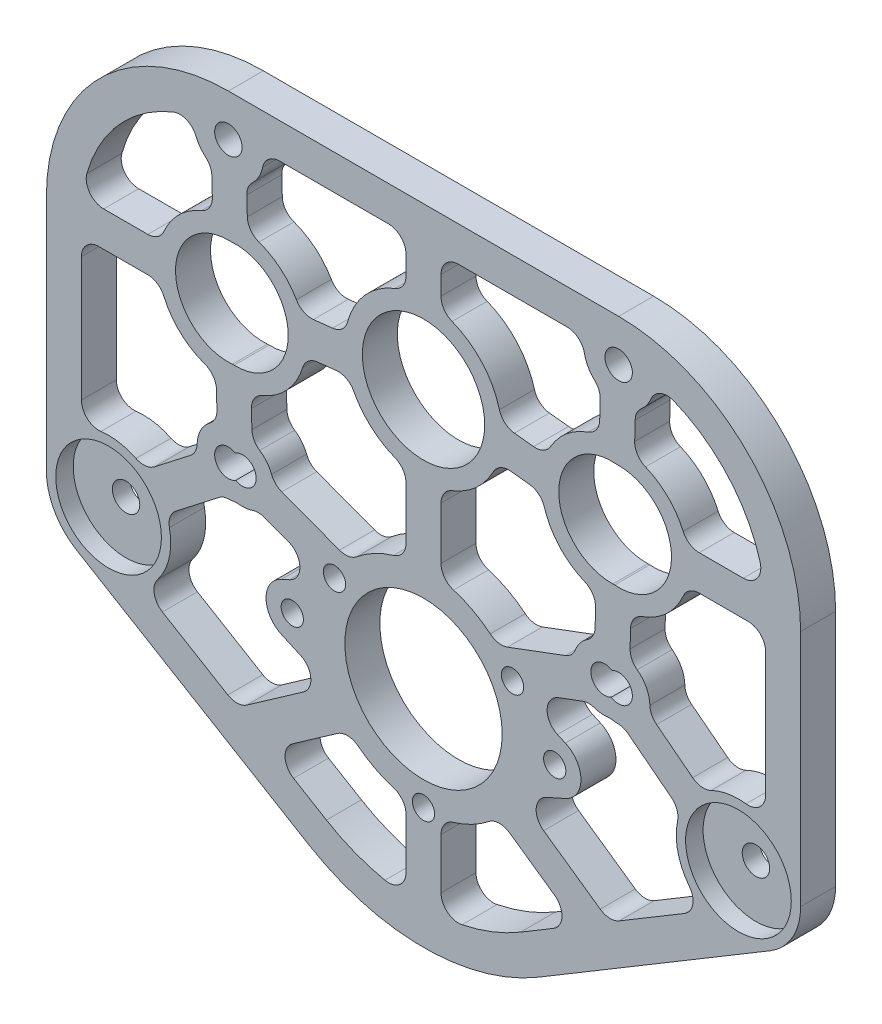
from build123d import *

# Parameters (mm, degrees)
BOSS_EXTRUDE1_DEPTH        = 6.35
M18_CLEARANCE_HOLE1_D      = 19.177
M18_CLEARANCE_HOLE1_DEPTH  = 6.35
M18_CLEARANCE_HOLE2_D      = 19.177
M18_CLEARANCE_HOLE2_DEPTH  = 6.35
CUT_EXTRUDE1_DEPTH         = 7.35
CUT_EXTRUDE2_DEPTH         = 7.35
CUT_EXTRUDE3_DEPTH         = 7.35
CUT_EXTRUDE4_DEPTH         = 7.35
CUT_EXTRUDE5_DEPTH         = 7.35
CUT_EXTRUDE6_DEPTH         = 7.35
CUT_EXTRUDE7_DEPTH         = 7.35
CUT_EXTRUDE8_DEPTH         = 7.35
CUT_EXTRUDE9_DEPTH         = 7.35
CUT_EXTRUDE10_DEPTH        = 7.35
CUT_EXTRUDE11_DEPTH        = 7.35
CUT_EXTRUDE12_DEPTH        = 7.35
SKETCH18_W                 = 9.5885
SKETCH18_H                 = 6.35
SKETCH19_W                 = 9.5885
SKETCH19_H                 = 6.35
M25_CLEARANCE_HOLE1_D      = 28.5496
M25_CLEARANCE_HOLE1_DEPTH  = 6.35
HOLE1_D                    = 4.9784
HOLE1_DEPTH                = 6.35
HOLE2_D                    = 4.9784
HOLE2_DEPTH                = 6.35
M20_CLEARANCE_HOLE1_D      = 22.1996
M20_CLEARANCE_HOLE1_DEPTH  = 6.35
M3_5_CLEARANCE_HOLE1_D     = 4.0386
M3_5_CLEARANCE_HOLE1_DEPTH = 6.35
HOLE3_D                    = 4.9784
HOLE3_DEPTH                = 6.35
HOLE3_CBORE_D              = 19.177
HOLE3_CBORE_DEPTH          = 3.175
FILLET1_R                  = 3.175
FILLET2_R                  = 11.28150672
FILLET3_R                  = 33.02
FILLET4_R                  = 40.64


with BuildPart() as part:
    # Sketch1 → Boss-Extrude1 (new body)
    with BuildSketch(Plane.XY.offset(3.175)):
        Polygon((0, -94.408741711), (68.43150672, -53.435111347), (68.43150672, 29.21), (-68.43150672, 29.21), (-68.43150672, -53.435111347), align=None)
    extrude(amount=-BOSS_EXTRUDE1_DEPTH)

    # M18 Clearance Hole1
    with Locations(Plane.XY.offset(3.175)):
        with Locations((34.132374495, -3.7777713)):
            Hole(M18_CLEARANCE_HOLE1_D / 2, depth=M18_CLEARANCE_HOLE1_DEPTH)

    # M18 Clearance Hole2
    with Locations(Plane.XY.offset(3.175)):
        with Locations((-34.132374495, -3.7777713)):
            Hole(M18_CLEARANCE_HOLE2_D / 2, depth=M18_CLEARANCE_HOLE2_DEPTH)

    # Sketch6 → Cut-Extrude1 (cut, through all)
    with BuildSketch(Plane.XY.offset(3.175)):
        with BuildLine():
            Line((17.615095968, -76.46039371), (23.582535178, -72.887366311))
            ThreePointArc((23.582535178, -72.887366311), (25.12448686, -70.276593795), (23.772612959, -67.562522116))
            Line((23.772612959, -67.562522116), (13.565480909, -60.415411311))
            ThreePointArc((13.565480909, -60.415411311), (8.796311082, -63.938356372), (3.175, -65.824353311))
            Line((3.175, -65.824353311), (3.175, -81.183492849))
            ThreePointArc((3.175, -81.183492849), (10.65992209, -79.631752135), (17.615095968, -76.46039371))
        make_face()
    extrude(amount=-CUT_EXTRUDE1_DEPTH, mode=Mode.SUBTRACT)

    # Sketch7 → Cut-Extrude2 (cut, through all)
    with BuildSketch(Plane.XY.offset(3.175)):
        with BuildLine():
            Line((31.913026081, 8.791294889), (32.098999956, 16.172454528))
            ThreePointArc((32.098999956, 16.172454528), (29.588611428, 19.056940502), (29.189802773, 22.86))
            Line((29.189802773, 22.86), (3.175, 22.86))
            Line((3.175, 22.86), (3.175, 13.91722997))
            ThreePointArc((3.175, 13.91722997), (10.627125942, 9.53069301), (14.179496739, 1.646750514))
            Line((14.179496739, 1.646750514), (22.206916622, 0.770897382))
            ThreePointArc((22.206916622, 0.770897382), (26.002148159, 6.061250602), (31.913026081, 8.791294889))
        make_face()
    extrude(amount=-CUT_EXTRUDE2_DEPTH, mode=Mode.SUBTRACT)

    # Sketch8 → Cut-Extrude3 (cut, through all)
    with BuildSketch(Plane.XY.offset(3.175)):
        with BuildLine():
            Line((13.435865001, -33.535984871), (27.242817605, -28.366892024))
            ThreePointArc((27.242817605, -28.366892024), (28.50767908, -25.512466465), (31.092824958, -23.761854968))
            Line((31.092824958, -23.761854968), (31.282869747, -16.219123917))
            ThreePointArc((31.282869747, -16.219123917), (24.724376238, -12.403111934), (21.49092773, -5.538667651))
            Line((21.49092773, -5.538667651), (13.490750449, -4.665786896))
            ThreePointArc((13.490750449, -4.665786896), (9.53069301, -10.627125942), (3.175, -13.91722997))
            Line((3.175, -13.91722997), (3.175, -28.257246689))
            ThreePointArc((3.175, -28.257246689), (8.714727662, -30.10102368), (13.435865001, -33.535984871))
        make_face()
    extrude(amount=-CUT_EXTRUDE3_DEPTH, mode=Mode.SUBTRACT)

    # Sketch9 → Cut-Extrude4 (cut, through all)
    with BuildSketch(Plane.XY.offset(3.175)):
        with BuildLine():
            Line((62.08150672, -6.985000553), (47.775965215, -6.97655939))
            ThreePointArc((47.775965215, -6.97655939), (44.087544958, -13.171265552), (37.630855133, -16.379066189))
            Line((37.630855133, -16.379066189), (37.440810345, -23.921797239))
            ThreePointArc((37.440810345, -23.921797239), (40.402375317, -26.531494393), (40.940094019, -30.442024396))
            Line((40.940094019, -30.442024396), (50.544309752, -37.895459645))
            ThreePointArc((50.544309752, -37.895459645), (56.174637648, -35.801535693), (62.08150672, -36.894242192))
            Line((62.08150672, -36.894242192), (62.08150672, -6.985000553))
        make_face()
    extrude(amount=-CUT_EXTRUDE4_DEPTH, mode=Mode.SUBTRACT)

    # Sketch10 → Cut-Extrude5 (cut, through all)
    with BuildSketch(Plane.XY.offset(3.175)):
        with BuildLine():
            Line((47.771628677, -0.626555725), (58.029583648, -0.63260856))
            ThreePointArc((58.029583648, -0.63260856), (60.561320425, 0.623949714), (61.088207147, 3.400822089))
            ThreePointArc((61.088207147, 3.400822089), (53.945197407, 15.367883343), (41.741154103, 22.098))
            ThreePointArc((41.741154103, 22.098), (40.995831795, 18.567118353), (38.446985343, 16.012512256))
            Line((38.446985343, 16.012512256), (38.261011468, 8.631352617))
            ThreePointArc((38.261011468, 8.631352617), (44.31433789, 5.335847659), (47.771628677, -0.626555725))
        make_face()
    extrude(amount=-CUT_EXTRUDE5_DEPTH, mode=Mode.SUBTRACT)

    # Sketch11 → Cut-Extrude6 (cut, through all)
    with BuildSketch(Plane.XY.offset(3.175)):
        with BuildLine():
            Line((-32.098999956, 16.172454528), (-31.913026081, 8.791294889))
            ThreePointArc((-31.913026081, 8.791294889), (-26.002148159, 6.061250602), (-22.206916622, 0.770897382))
            Line((-22.206916622, 0.770897382), (-14.179496739, 1.646750514))
            ThreePointArc((-14.179496739, 1.646750514), (-10.627125942, 9.53069301), (-3.175, 13.91722997))
            Line((-3.175, 13.91722997), (-3.175, 22.86))
            Line((-3.175, 22.86), (-29.189802773, 22.86))
            ThreePointArc((-29.189802773, 22.86), (-29.588611428, 19.056940502), (-32.098999956, 16.172454528))
        make_face()
    extrude(amount=-CUT_EXTRUDE6_DEPTH, mode=Mode.SUBTRACT)

    # Sketch12 → Cut-Extrude7 (cut, through all)
    with BuildSketch(Plane.XY.offset(3.175)):
        with BuildLine():
            Line((-47.775965215, -6.97655939), (-62.08150672, -6.985000553))
            Line((-62.08150672, -6.985000553), (-62.08150672, -36.894242192))
            ThreePointArc((-62.08150672, -36.894242192), (-56.174637648, -35.801535693), (-50.544309752, -37.895459645))
            Line((-50.544309752, -37.895459645), (-40.940094019, -30.442024396))
            ThreePointArc((-40.940094019, -30.442024396), (-40.402375317, -26.531494393), (-37.440810345, -23.921797239))
            Line((-37.440810345, -23.921797239), (-37.630855133, -16.379066189))
            ThreePointArc((-37.630855133, -16.379066189), (-44.087544958, -13.171265552), (-47.775965215, -6.97655939))
        make_face()
    extrude(amount=-CUT_EXTRUDE7_DEPTH, mode=Mode.SUBTRACT)

    # Sketch13 → Cut-Extrude8 (cut, through all)
    with BuildSketch(Plane.XY.offset(3.175)):
        with BuildLine():
            Line((-38.261011468, 8.631352617), (-38.446985343, 16.012512256))
            ThreePointArc((-38.446985343, 16.012512256), (-40.995831795, 18.567118353), (-41.741154103, 22.098))
            ThreePointArc((-41.741154103, 22.098), (-53.945197407, 15.367883343), (-61.088207147, 3.400822089))
            ThreePointArc((-61.088207147, 3.400822089), (-60.561320425, 0.623949714), (-58.029583648, -0.63260856))
            Line((-58.029583648, -0.63260856), (-47.771628677, -0.626555725))
            ThreePointArc((-47.771628677, -0.626555725), (-44.31433789, 5.335847659), (-38.261011468, 8.631352617))
        make_face()
    extrude(amount=-CUT_EXTRUDE8_DEPTH, mode=Mode.SUBTRACT)

    # Sketch14 → Cut-Extrude9 (cut, through all)
    with BuildSketch(Plane.XY.offset(3.175)):
        with BuildLine():
            Line((-27.242817605, -28.366892024), (-13.435865001, -33.535984871))
            ThreePointArc((-13.435865001, -33.535984871), (-8.714727662, -30.10102368), (-3.175, -28.257246689))
            Line((-3.175, -28.257246689), (-3.175, -13.91722997))
            ThreePointArc((-3.175, -13.91722997), (-9.53069301, -10.627125942), (-13.490750449, -4.665786896))
            Line((-13.490750449, -4.665786896), (-21.49092773, -5.538667651))
            ThreePointArc((-21.49092773, -5.538667651), (-24.724376238, -12.403111934), (-31.282869747, -16.219123917))
            Line((-31.282869747, -16.219123917), (-31.092824958, -23.761854968))
            ThreePointArc((-31.092824958, -23.761854968), (-28.50767908, -25.512466465), (-27.242817605, -28.366892024))
        make_face()
    extrude(amount=-CUT_EXTRUDE9_DEPTH, mode=Mode.SUBTRACT)

    # Sketch15 → Cut-Extrude10 (cut, through all)
    with BuildSketch(Plane.XY.offset(3.175)):
        with BuildLine():
            Line((-13.565480909, -60.415411311), (-23.772612959, -67.562522116))
            ThreePointArc((-23.772612959, -67.562522116), (-25.12448686, -70.276593795), (-23.582535178, -72.887366311))
            Line((-23.582535178, -72.887366311), (-17.615095968, -76.46039371))
            ThreePointArc((-17.615095968, -76.46039371), (-10.65992209, -79.631752135), (-3.175, -81.183492849))
            Line((-3.175, -81.183492849), (-3.175, -65.824353311))
            ThreePointArc((-3.175, -65.824353311), (-8.796311082, -63.938356372), (-13.565480909, -60.415411311))
        make_face()
    extrude(amount=-CUT_EXTRUDE10_DEPTH, mode=Mode.SUBTRACT)

    # Sketch16 → Cut-Extrude11 (cut, through all)
    with BuildSketch(Plane.XY.offset(3.175)):
        with BuildLine():
            Line((-22.318905678, -52.92668905), (-25.757705391, -51.387934946))
            ThreePointArc((-25.757705391, -51.387934946), (-28.574996604, -47.035112368), (-25.747316689, -42.689031322))
            Line((-25.747316689, -42.689031322), (-24.314652477, -42.052062118))
            ThreePointArc((-24.314652477, -42.052062118), (-22.430965024, -39.055443853), (-24.491321085, -36.177435453))
            Line((-24.491321085, -36.177435453), (-30.080779683, -34.084835349))
            ThreePointArc((-30.080779683, -34.084835349), (-31.982139058, -34.742357841), (-33.993393871, -34.693805028))
            ThreePointArc((-33.993393871, -34.693805028), (-35.100270784, -34.865642654), (-36.219319476, -34.816300045))
            Line((-36.219319476, -34.816300045), (-46.651162402, -42.912022583))
            ThreePointArc((-46.651162402, -42.912022583), (-46.401481265, -50.467422079), (-50.977977716, -56.484238717))
            Line((-50.977977716, -56.484238717), (-33.752087956, -66.798307098))
            Line((-33.752087956, -66.798307098), (-21.794604087, -58.425586755))
            ThreePointArc((-21.794604087, -58.425586755), (-20.455043555, -55.523420059), (-22.318905678, -52.92668905))
        make_face()
    extrude(amount=-CUT_EXTRUDE11_DEPTH, mode=Mode.SUBTRACT)

    # Sketch17 → Cut-Extrude12 (cut, through all)
    with BuildSketch(Plane(origin=(0, 0, -3.175), x_dir=(-1, 0, 0), z_dir=(0, 0, -1))):
        with BuildLine():
            Line((-33.752087956, -66.798307098), (-21.794604087, -58.425586755))
            ThreePointArc((-21.794604087, -58.425586755), (-20.455043555, -55.523420059), (-22.318905678, -52.92668905))
            Line((-22.318905678, -52.92668905), (-25.757705391, -51.387934946))
            ThreePointArc((-25.757705391, -51.387934946), (-28.574996604, -47.035112368), (-25.747316689, -42.689031322))
            Line((-25.747316689, -42.689031322), (-24.314652477, -42.052062118))
            ThreePointArc((-24.314652477, -42.052062118), (-22.430965024, -39.055443853), (-24.491321085, -36.177435453))
            Line((-24.491321085, -36.177435453), (-30.080779683, -34.084835349))
            ThreePointArc((-30.080779683, -34.084835349), (-31.982139058, -34.742357841), (-33.993393871, -34.693805028))
            ThreePointArc((-33.993393871, -34.693805028), (-35.100270784, -34.865642654), (-36.219319476, -34.816300045))
            Line((-36.219319476, -34.816300045), (-46.651162402, -42.912022583))
            ThreePointArc((-46.651162402, -42.912022583), (-46.401481265, -50.467422079), (-50.977977716, -56.484238717))
            Line((-50.977977716, -56.484238717), (-33.752087956, -66.798307098))
        make_face()
    extrude(amount=-CUT_EXTRUDE12_DEPTH, mode=Mode.SUBTRACT)

    # Sketch18 → Cut-Revolve1 (revolve, cut)
    with BuildSketch(Plane(origin=(0, -3.81, 0), x_dir=(1, 0, 0), z_dir=(0, 1, 0))):
        with Locations((40.20575672, 0)):
            Rectangle(SKETCH18_W, SKETCH18_H)
    revolve(axis=Axis((35.41150672, -3.81, -3.175), (0, 0, 1)), mode=Mode.SUBTRACT)

    # Sketch19 → Cut-Revolve2 (revolve, cut)
    with BuildSketch(Plane.XZ.offset(3.81)):
        with Locations((-30.61725672, 0)):
            Rectangle(SKETCH19_W, SKETCH19_H)
    revolve(axis=Axis((-35.41150672, -3.81, 3.175), (0, 0, -1)), mode=Mode.SUBTRACT)

    # M25 Clearance Hole1
    with Locations(Plane.XY.offset(3.175)):
        with Locations((0, -47.0408)):
            Hole(M25_CLEARANCE_HOLE1_D / 2, depth=M25_CLEARANCE_HOLE1_DEPTH)

    # Hole1
    with Locations(Plane.XY.offset(3.175)):
        with Locations((35.41150672, -29.21), (-32.853242269, -29.145542601), (-35.41150672, 21.59), (35.41150672, 21.59)):
            Hole(HOLE1_D / 2, depth=HOLE1_DEPTH)

    # Hole2
    with Locations(Plane(origin=(0, 0, -3.175), x_dir=(-1, 0, 0), z_dir=(0, 0, -1))):
        with Locations((-32.853242269, -29.145542601), (35.41150672, -29.21)):
            Hole(HOLE2_D / 2, depth=HOLE2_DEPTH)

    # M20 Clearance Hole1
    with Locations(Plane.XY.offset(3.175)):
        with Locations((0, 0)):
            Hole(M20_CLEARANCE_HOLE1_D / 2, depth=M20_CLEARANCE_HOLE1_DEPTH)

    # M3.5 Clearance Hole1
    with Locations(Plane.XY.offset(3.175)):
        with Locations((0, -65.693925), (-16.15408011, -37.7142375), (16.15408011, -37.7142375), (-23.8125, -47.0408), (23.8125, -47.0408)):
            Hole(M3_5_CLEARANCE_HOLE1_D / 2, depth=M3_5_CLEARANCE_HOLE1_DEPTH)

    # Hole3
    with Locations(Plane.XY.offset(3.175)):
        with Locations((57.15, -47.0408), (-57.15, -47.0408)):
            CounterBoreHole(HOLE3_D / 2, HOLE3_CBORE_D / 2, HOLE3_CBORE_DEPTH, depth=HOLE3_DEPTH)

    # Fillet1
    fillet1_edges = [part.edges().sort_by_distance(p)[0] for p in [
        (62.08150672, -6.985000553, 0),
        (62.08150672, -36.894242192, 0),
        (50.544309752, -37.895459645, 0),
        (40.940094019, -30.442024396, 0),
        (37.440810345, -23.921797239, 0),
        (37.630855133, -16.379066189, 0),
        (47.775965215, -6.97655939, 0),
        (47.771628677, -0.626555725, 0),
        (38.261011468, 8.631352617, 0),
        (38.446985343, 16.012512256, 0),
        (41.741154103, 22.098, 0),
        (-32.098999956, 16.172454528, 0),
        (-29.189802773, 22.86, 0),
        (-3.175, 22.86, 0),
        (-3.175, 13.91722997, 0),
        (-14.179496739, 1.646750514, 0),
        (-22.206916622, 0.770897382, 0),
        (-31.913026081, 8.791294889, 0),
        (-47.775965215, -6.97655939, 0),
        (-37.630855133, -16.379066189, 0),
        (-37.440810345, -23.921797239, 0),
        (-40.940094019, -30.442024396, 0),
        (-50.544309752, -37.895459645, 0),
        (-62.08150672, -36.894242192, 0),
        (-62.08150672, -6.985000553, 0),
        (-38.261011468, 8.631352617, 0),
        (-47.771628677, -0.626555725, 0),
        (-41.741154103, 22.098, 0),
        (-38.446985343, 16.012512256, 0),
        (-27.242817605, -28.366892024, 0),
        (-31.092824958, -23.761854968, 0),
        (-31.282869747, -16.219123917, 0),
        (-21.49092773, -5.538667651, 0),
        (-13.490750449, -4.665786896, 0),
        (-3.175, -13.91722997, 0),
        (-3.175, -28.257246689, 0),
        (-13.435865001, -33.535984871, 0),
        (-13.565480909, -60.415411311, 0),
        (-3.175, -65.824353311, 0),
        (-3.175, -81.183492849, 0),
        (-33.752087956, -66.798307098, 0),
        (-50.977977716, -56.484238717, 0),
        (-46.651162402, -42.912022583, 0),
        (-36.219319476, -34.816300045, 0),
        (-33.993393871, -34.693805028, 0),
        (-30.080779683, -34.084835349, 0),
        (3.175, -81.183492849, 0),
        (3.175, -65.824353311, 0),
        (33.752087956, -66.798307098, 0),
        (50.977977716, -56.484238717, 0),
        (13.565480909, -60.415411311, 0),
        (46.651162402, -42.912022583, 0),
        (36.219319476, -34.816300045, 0),
        (33.993393871, -34.693805028, 0),
        (30.080779683, -34.084835349, 0),
        (34.530965969, -13.357983045, 0),
        (35.012915246, 5.770211745, 0),
        (-35.012915246, 5.770211745, 0),
        (-34.530965969, -13.357983045, 0),
        (31.913026081, 8.791294889, 0),
        (22.206916622, 0.770897382, 0),
        (14.179496739, 1.646750514, 0),
        (3.175, 13.91722997, 0),
        (3.175, 22.86, 0),
        (29.189802773, 22.86, 0),
        (32.098999956, 16.172454528, 0),
        (13.435865001, -33.535984871, 0),
        (3.175, -28.257246689, 0),
        (3.175, -13.91722997, 0),
        (13.490750449, -4.665786896, 0),
        (21.49092773, -5.538667651, 0),
        (31.282869747, -16.219123917, 0),
        (31.092824958, -23.761854968, 0),
        (27.242817605, -28.366892024, 0),
    ]]
    fillet(fillet1_edges, radius=FILLET1_R)

    # Fillet2
    fillet2_edges = [part.edges().sort_by_distance(p)[0] for p in [
        (-68.43150672, -53.435111347, 0),
        (68.43150672, -53.435111347, 0),
    ]]
    fillet(fillet2_edges, radius=FILLET2_R)

    # Fillet3
    fillet3_edges = [part.edges().sort_by_distance(p)[0] for p in [
        (-68.43150672, 29.21, 0),
        (68.43150672, 29.21, 0),
    ]]
    fillet(fillet3_edges, radius=FILLET3_R)

    # Fillet4
    fillet4_edges = [part.edges().sort_by_distance(p)[0] for p in [
        (0, -94.408741711, 0),
    ]]
    fillet(fillet4_edges, radius=FILLET4_R)


solid = part.part
